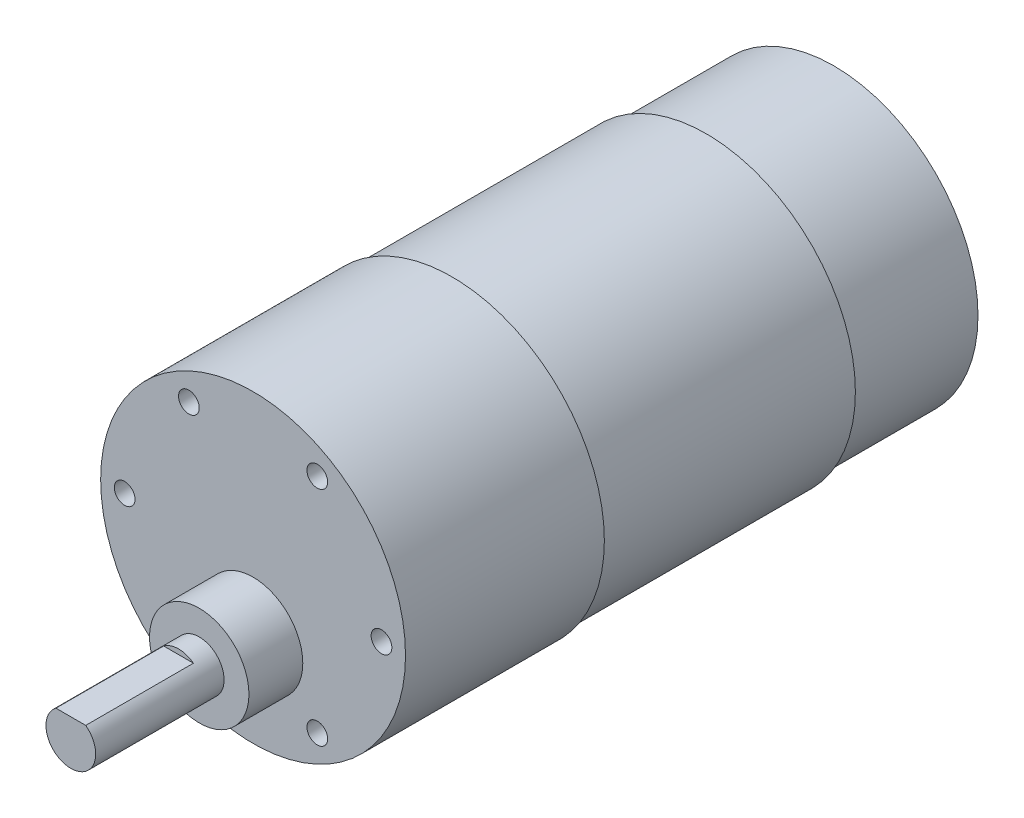
from build123d import *

# Parameters (mm, degrees)
SKETCH1_R                       = 17.4
BOSS_EXTRUDE1_DEPTH             = 15.4
SKETCH2_R                       = 18
BOSS_EXTRUDE2_DEPTH             = 30.7
SKETCH3_R                       = 18.4
BOSS_EXTRUDE3_DEPTH             = 24
SKETCH4_R                       = 6
BOSS_EXTRUDE4_DEPTH             = 6.5
SKETCH5_R                       = 3
BOSS_EXTRUDE5_DEPTH             = 15.5
CUT_EXTRUDE1_DEPTH              = 13
TAP_DRILL_FOR_M3X0_5_TAP1_D     = 2.5
TAP_DRILL_FOR_M3X0_5_TAP1_DEPTH = 10.76


with BuildPart() as part:
    # Sketch1 → Boss-Extrude1 (new body)
    with BuildSketch(Plane.XY):
        Circle(SKETCH1_R)
    extrude(amount=BOSS_EXTRUDE1_DEPTH)

    # Sketch2 → Boss-Extrude2 (add)
    with BuildSketch(Plane.XY.offset(15.4)):
        Circle(SKETCH2_R)
    extrude(amount=BOSS_EXTRUDE2_DEPTH)

    # Sketch3 → Boss-Extrude3 (add)
    with BuildSketch(Plane.XY.offset(46.1)):
        Circle(SKETCH3_R)
    extrude(amount=BOSS_EXTRUDE3_DEPTH)

    # Sketch4 → Boss-Extrude4 (add)
    with BuildSketch(Plane.XY.offset(70.1)):
        with Locations((0, -7)):
            Circle(SKETCH4_R)
    extrude(amount=BOSS_EXTRUDE4_DEPTH)

    # Sketch5 → Boss-Extrude5 (add)
    with BuildSketch(Plane.XY.offset(76.6)):
        with Locations((0, -7)):
            Circle(SKETCH5_R)
    extrude(amount=BOSS_EXTRUDE5_DEPTH)

    # Sketch6 → Cut-Extrude1 (cut)
    with BuildSketch(Plane.XY.offset(92.1)):
        with BuildLine():
            Line((-1.8, -4.6), (1.8, -4.6))
            ThreePointArc((1.8, -4.6), (0, -4), (-1.8, -4.6))
        make_face()
    extrude(amount=-CUT_EXTRUDE1_DEPTH, mode=Mode.SUBTRACT)

    # Tap Drill for M3x0.5 Tap1
    with Locations(Plane.XY.offset(70.1)):
        with Locations((-15.5, 0), (-7.75, 13.423393759), (7.75, 13.423393759), (15.5, 0), (7.75, -13.423393759), (-7.75, -13.423393759)):
            Hole(TAP_DRILL_FOR_M3X0_5_TAP1_D / 2, depth=TAP_DRILL_FOR_M3X0_5_TAP1_DEPTH)


solid = part.part
